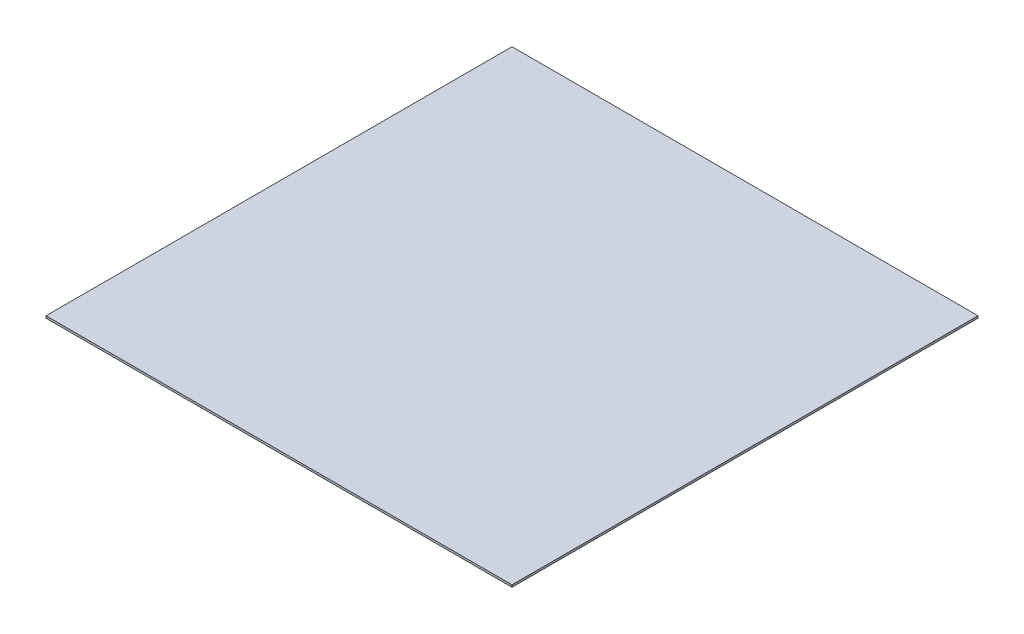
from build123d import *

# Parameters (mm, degrees)
SKETCH1_W           = 558.8
SKETCH1_H           = 558.8
BOSS_EXTRUDE1_DEPTH = 2.54


with BuildPart() as part:
    # Sketch1 → Boss-Extrude1 (new body)
    with BuildSketch(Plane(origin=(0, 0, 0), x_dir=(1, 0, 0), z_dir=(0, 1, 0))):
        with Locations((279.4, -279.4)):
            Rectangle(SKETCH1_W, SKETCH1_H)
    extrude(amount=BOSS_EXTRUDE1_DEPTH)


solid = part.part
